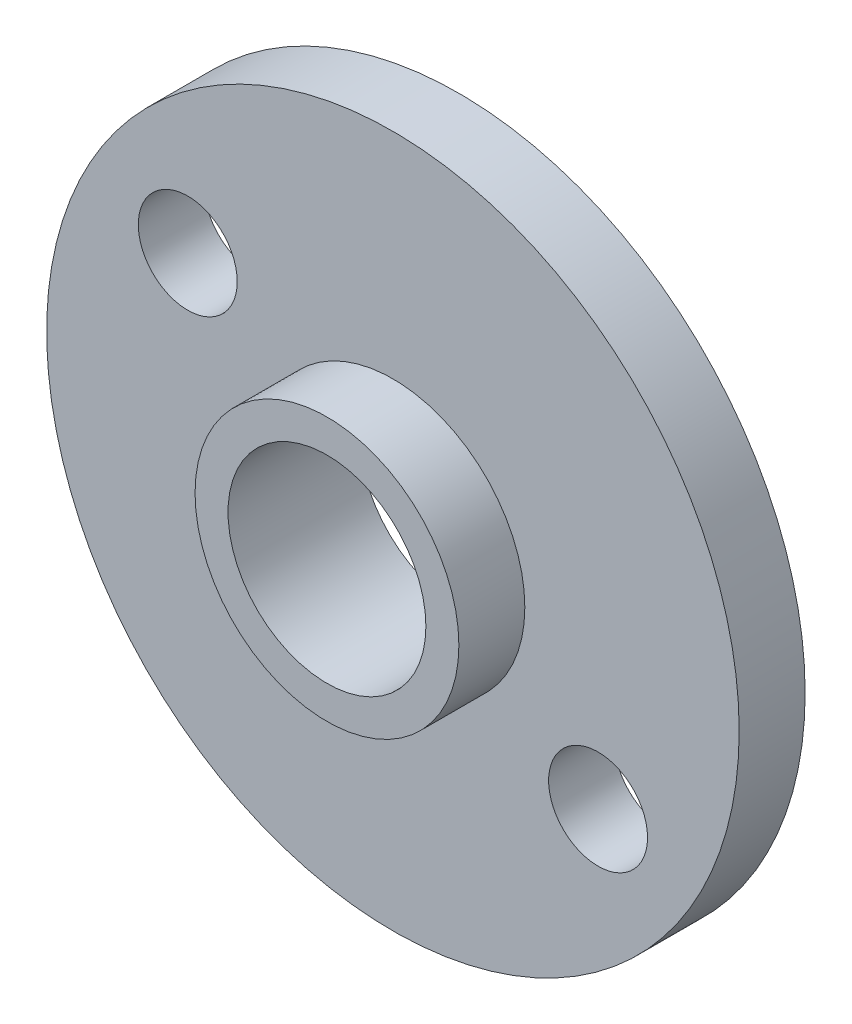
from build123d import *

# Parameters (mm, degrees)
MODEL_R                 = 10.5
MODEL_R_2               = 3
SALIENTE_EXTRUIR1_DEPTH = 2
CORTAR_EXTRUIR1_REACH   = 4
CROQUIS2_R              = 1.5
CROQUIS3_R              = 4.000000302
CROQUIS3_R_2            = 3
SALIENTE_EXTRUIR2_DEPTH = 2


with BuildPart() as part:
    # Model → Saliente-Extruir1 (new body)
    with BuildSketch(Plane.XY):
        with Locations((162.8, 159.569296)):
            Circle(MODEL_R)
        with Locations((162.8, 159.569296)):
            Circle(MODEL_R_2, mode=Mode.SUBTRACT)
    extrude(amount=SALIENTE_EXTRUIR1_DEPTH)

    # Croquis2 → Cortar-Extruir1 (cut, up to next)
    with BuildSketch(Plane.XY.offset(2), mode=Mode.PRIVATE) as cortar_extruir1_sk1:
        with Locations((156.57897681, 163.758432659)):
            Circle(CROQUIS2_R)
    cortar_extruir1_tool1 = extrude(cortar_extruir1_sk1.sketch, amount=-CORTAR_EXTRUIR1_REACH, mode=Mode.PRIVATE) & part.part
    add(cortar_extruir1_tool1.solids().sort_by_distance((156.578977, 163.758433, 2))[0], mode=Mode.SUBTRACT)
    # Croquis2 → Cortar-Extruir1 (cut, up to next)
    with BuildSketch(Plane.XY.offset(2), mode=Mode.PRIVATE) as cortar_extruir1_sk2:
        with Locations((169.021023816, 155.380159191)):
            Circle(CROQUIS2_R)
    cortar_extruir1_tool2 = extrude(cortar_extruir1_sk2.sketch, amount=-CORTAR_EXTRUIR1_REACH, mode=Mode.PRIVATE) & part.part
    add(cortar_extruir1_tool2.solids().sort_by_distance((169.021024, 155.380159, 2))[0], mode=Mode.SUBTRACT)

    # Croquis3 → Saliente-Extruir2 (add)
    with BuildSketch(Plane.XY.offset(2)):
        with Locations((162.8, 159.569296)):
            Circle(CROQUIS3_R)
        with Locations((162.8, 159.569296)):
            Circle(CROQUIS3_R_2, mode=Mode.SUBTRACT)
    extrude(amount=SALIENTE_EXTRUIR2_DEPTH)


solid = part.part
